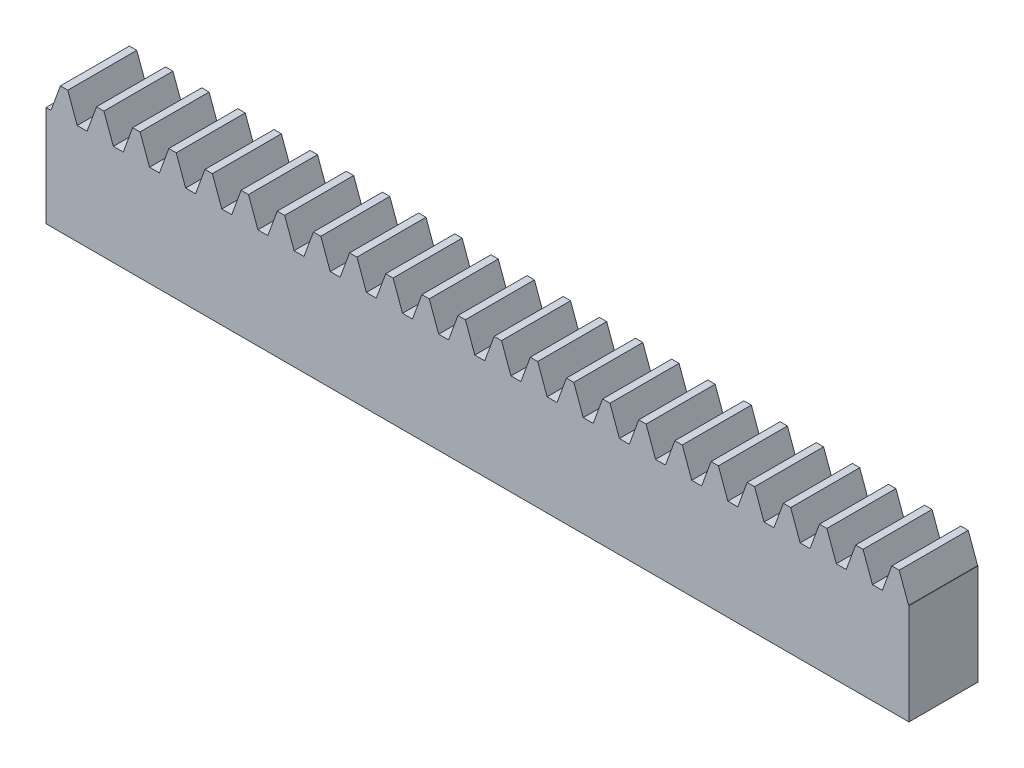
from build123d import *

# Parameters (mm, degrees)
BLANKSKE_W        = 150
BLANKSKE_H        = 22
BLANK_DEPTH       = 12
TOOTHCUTSIM_DEPTH = 153.078926877
TEETHCUTS_COUNT   = 25
TEETHCUTS_PITCH   = 6.2831853


with BuildPart() as part:
    # BlankSke → Blank (new body)
    with BuildSketch(Plane.XY):
        with Locations((75, 11)):
            Rectangle(BLANKSKE_W, BLANKSKE_H)
    extrude(amount=-BLANK_DEPTH)

    # TooCutSkeSim → ToothCutSim (cut, through all)
    with BuildSketch(Plane.XY):
        Polygon((0.861870739, 17.5), (-0.861870739, 17.5), (-2.508981637, 22.0254), (2.508981637, 22.0254), align=None)
    toothcutsim = extrude(amount=-TOOTHCUTSIM_DEPTH, mode=Mode.SUBTRACT)

    # TeethCuts: ToothCutSim ×25
    with Locations(*[(i * TEETHCUTS_PITCH, 0, 0) for i in range(1, TEETHCUTS_COUNT)]):
        add(toothcutsim, mode=Mode.SUBTRACT)


solid = part.part
